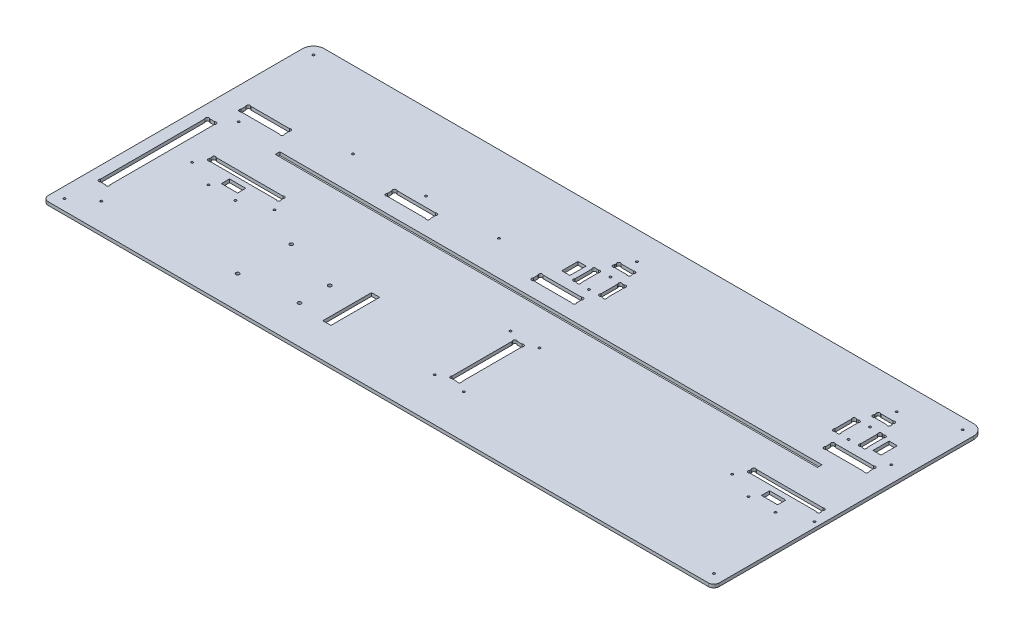
from build123d import *

# Parameters (mm, degrees)
ESQUISSE1_R             = 1
EXTRUSION1_DEPTH        = 3
ESQUISSE2_W             = 501
ESQUISSE2_H             = 4.2
ENL_V_MAT_EXTRU_1_DEPTH = 4
ESQUISSE3_R             = 1
ENL_V_MAT_EXTRU_2_DEPTH = 4
CONG_1_R                = 5
ESQUISSE4_R             = 1
ENL_V_MAT_EXTRU_3_DEPTH = 4
ESQUISSE5_R             = 1.59
ENL_V_MAT_EXTRU_4_DEPTH = 4
ESQUISSE6_W             = 15
ESQUISSE6_H             = 7.5
ESQUISSE6_W_2           = 7.5
ESQUISSE6_H_2           = 15
ESQUISSE6_H_3           = 45
ENL_V_MAT_EXTRU_5_DEPTH = 4
ESQUISSE7_R             = 1
ENL_V_MAT_EXTRU_6_DEPTH = 4
ESQUISSE8_R             = 1
ENL_V_MAT_EXTRU_7_DEPTH = 4


with BuildPart() as part:
    # Esquisse1 → Extrusion1 (new body)
    with BuildSketch(Plane(origin=(0, 0, 0), x_dir=(1, 0, 0), z_dir=(0, 1, 0))):
        with BuildLine():
            Line((10, 250), (610, 250))
            ThreePointArc((610, 250), (617.071067812, 247.071067812), (620, 240))
            Line((620, 240), (620, 0))
            Line((620, 0), (0, 0))
            Line((0, 0), (0, 240))
            ThreePointArc((0, 240), (2.928932188, 247.071067812), (10, 250))
        make_face()
        with Locations(Location((539, 98, 0), (0, 0, 270))):  # turned: the seam where the file's is
            Circle(ESQUISSE1_R, mode=Mode.SUBTRACT)
        with Locations(Location((615, 98, 0), (0, 0, 270))):  # turned: the seam where the file's is
            Circle(ESQUISSE1_R, mode=Mode.SUBTRACT)
        with BuildLine():
            Line((317, 211.2627417), (317, 212.7372583))
            ThreePointArc((317, 212.7372583), (317, 215), (319.2627417, 215))
            Line((319.2627417, 215), (330.7372583, 215))
            ThreePointArc((330.7372583, 215), (333, 215), (333, 212.7372583))
            Line((333, 212.7372583), (333, 211.2627417))
            ThreePointArc((333, 211.2627417), (333, 209), (330.737258301, 209))
            Line((330.737258301, 209), (319.262741699, 209))
            ThreePointArc((319.262741699, 209), (316.999999999, 209.000000001), (317, 211.2627417))
        make_face(mode=Mode.SUBTRACT)
        with BuildLine():
            Line((312.262741699, 179.5), (313.737258301, 179.5))
            ThreePointArc((313.737258301, 179.5), (316.000000001, 179.500000001), (316, 181.762741701))
            Line((316, 181.762741701), (316, 197.237258299))
            ThreePointArc((316, 197.237258299), (316.000000001, 199.499999999), (313.737258301, 199.5))
            Line((313.737258301, 199.5), (312.262741699, 199.5))
            ThreePointArc((312.262741699, 199.5), (309.999999999, 199.499999999), (310, 197.237258299))
            Line((310, 197.237258299), (310, 181.762741701))
            ThreePointArc((310, 181.762741701), (309.999999999, 179.500000001), (312.262741699, 179.5))
        make_face(mode=Mode.SUBTRACT)
        with BuildLine():
            Line((334, 181.762741701), (334, 197.2372583))
            ThreePointArc((334, 197.2372583), (334, 199.5), (336.2627417, 199.5))
            Line((336.2627417, 199.5), (337.7372583, 199.5))
            ThreePointArc((337.7372583, 199.5), (340, 199.5), (340, 197.2372583))
            Line((340, 197.2372583), (340, 181.762741701))
            ThreePointArc((340, 181.762741701), (340.000000001, 179.500000001), (337.737258301, 179.5))
            Line((337.737258301, 179.5), (336.262741699, 179.5))
            ThreePointArc((336.262741699, 179.5), (333.999999999, 179.500000001), (334, 181.762741701))
        make_face(mode=Mode.SUBTRACT)
        with BuildLine():
            Line((552.2627417, 179.5), (553.7372583, 179.5))
            ThreePointArc((553.7372583, 179.5), (556, 179.5), (556, 181.7627417))
            Line((556, 181.7627417), (556, 197.2372583))
            ThreePointArc((556, 197.2372583), (556, 199.5), (553.7372583, 199.5))
            Line((553.7372583, 199.5), (552.2627417, 199.5))
            ThreePointArc((552.2627417, 199.5), (550, 199.5), (550, 197.2372583))
            Line((550, 197.2372583), (550, 181.7627417))
            ThreePointArc((550, 181.7627417), (550, 179.5), (552.2627417, 179.5))
        make_face(mode=Mode.SUBTRACT)
        with BuildLine():
            Line((574, 181.7627417), (574, 197.2372583))
            ThreePointArc((574, 197.2372583), (574, 199.5), (576.2627417, 199.5))
            Line((576.2627417, 199.5), (577.7372583, 199.5))
            ThreePointArc((577.7372583, 199.5), (580, 199.5), (580, 197.2372583))
            Line((580, 197.2372583), (580, 181.7627417))
            ThreePointArc((580, 181.7627417), (580, 179.5), (577.7372583, 179.5))
            Line((577.7372583, 179.5), (576.2627417, 179.5))
            ThreePointArc((576.2627417, 179.5), (574, 179.5), (574, 181.7627417))
        make_face(mode=Mode.SUBTRACT)
        with BuildLine():
            Line((559.2627417, 209), (570.7372583, 209))
            ThreePointArc((570.7372583, 209), (573, 209), (573, 211.2627417))
            Line((573, 211.2627417), (573, 212.7372583))
            ThreePointArc((573, 212.7372583), (573, 215), (570.7372583, 215))
            Line((570.7372583, 215), (559.2627417, 215))
            ThreePointArc((559.2627417, 215), (557, 215), (557, 212.7372583))
            Line((557, 212.7372583), (557, 211.2627417))
            ThreePointArc((557, 211.2627417), (557, 209), (559.2627417, 209))
        make_face(mode=Mode.SUBTRACT)
        with BuildLine():
            Line((560, 167.7372583), (560, 163.2627417))
            ThreePointArc((560, 163.2627417), (560, 161), (562.2627417, 161))
            Line((562.2627417, 161), (597.7372583, 161))
            ThreePointArc((597.7372583, 161), (600, 161), (600, 163.2627417))
            Line((600, 163.2627417), (600, 167.7372583))
            ThreePointArc((600, 167.7372583), (600, 170), (597.7372583, 170))
            Line((597.7372583, 170), (562.2627417, 170))
            ThreePointArc((562.2627417, 170), (560, 170), (560, 167.7372583))
        make_face(mode=Mode.SUBTRACT)
        with BuildLine():
            Line((292.2627417, 161), (327.7372583, 161))
            ThreePointArc((327.7372583, 161), (330, 161), (330, 163.2627417))
            Line((330, 163.2627417), (330, 167.7372583))
            ThreePointArc((330, 167.7372583), (330, 170), (327.7372583, 170))
            Line((327.7372583, 170), (292.2627417, 170))
            ThreePointArc((292.2627417, 170), (290, 170), (290, 167.7372583))
            Line((290, 167.7372583), (290, 163.2627417))
            ThreePointArc((290, 163.2627417), (290, 161), (292.2627417, 161))
        make_face(mode=Mode.SUBTRACT)
        with BuildLine():
            Line((20, 167.7372583), (20, 163.2627417))
            ThreePointArc((20, 163.2627417), (20, 161), (22.2627417, 161))
            Line((22.2627417, 161), (57.7372583, 161))
            ThreePointArc((57.7372583, 161), (60, 161), (60, 163.2627417))
            Line((60, 163.2627417), (60, 167.7372583))
            ThreePointArc((60, 167.7372583), (60, 170), (57.7372583, 170))
            Line((57.7372583, 170), (22.2627417, 170))
            ThreePointArc((22.2627417, 170), (20, 170), (20, 167.7372583))
        make_face(mode=Mode.SUBTRACT)
        with BuildLine():
            Line((155, 167.7372583), (155, 163.2627417))
            ThreePointArc((155, 163.2627417), (155, 161), (157.2627417, 161))
            Line((157.2627417, 161), (192.7372583, 161))
            ThreePointArc((192.7372583, 161), (195, 161), (195, 163.2627417))
            Line((195, 163.2627417), (195, 167.7372583))
            ThreePointArc((195, 167.7372583), (195, 170), (192.7372583, 170))
            Line((192.7372583, 170), (157.2627417, 170))
            ThreePointArc((157.2627417, 170), (155, 170), (155, 167.7372583))
        make_face(mode=Mode.SUBTRACT)
        with BuildLine():
            Line((13.2627417, 40), (17.7372583, 40))
            ThreePointArc((17.7372583, 40), (20, 40), (20, 42.2627417))
            Line((20, 42.2627417), (20, 138.7372583))
            ThreePointArc((20, 138.7372583), (20, 141), (17.7372583, 141))
            Line((17.7372583, 141), (13.2627417, 141))
            ThreePointArc((13.2627417, 141), (11, 141), (11, 138.7372583))
            Line((11, 138.7372583), (11, 42.2627417))
            ThreePointArc((11, 42.2627417), (11, 40), (13.2627417, 40))
        make_face(mode=Mode.SUBTRACT)
        with BuildLine():
            Line((337.7372583, 45), (333.2627417, 45))
            ThreePointArc((333.2627417, 45), (331, 45), (331, 47.2627417))
            Line((331, 47.2627417), (331, 102.7372583))
            ThreePointArc((331, 102.7372583), (331, 105), (333.2627417, 105))
            Line((333.2627417, 105), (337.7372583, 105))
            ThreePointArc((337.7372583, 105), (340, 105), (340, 102.7372583))
            Line((340, 102.7372583), (340, 47.2627417))
            ThreePointArc((340, 47.2627417), (340, 45), (337.7372583, 45))
        make_face(mode=Mode.SUBTRACT)
        with BuildLine():
            Line((610, 109.2627417), (610, 110.7372583))
            ThreePointArc((610, 110.7372583), (610, 113), (607.7372583, 113))
            Line((607.7372583, 113), (546.2627417, 113))
            ThreePointArc((546.2627417, 113), (544, 113), (544, 110.7372583))
            Line((544, 110.7372583), (544, 109.2627417))
            ThreePointArc((544, 109.2627417), (544, 107), (546.2627417, 107))
            Line((546.2627417, 107), (607.7372583, 107))
            ThreePointArc((607.7372583, 107), (610, 107), (610, 109.2627417))
        make_face(mode=Mode.SUBTRACT)
        with BuildLine():
            Line((108.7372583, 113), (47.2627417, 113))
            ThreePointArc((47.2627417, 113), (45, 113), (45, 110.7372583))
            Line((45, 110.7372583), (45, 109.2627417))
            ThreePointArc((45, 109.2627417), (45, 107), (47.2627417, 107))
            Line((47.2627417, 107), (108.7372583, 107))
            ThreePointArc((108.7372583, 107), (111, 107), (111, 109.2627417))
            Line((111, 109.2627417), (111, 110.7372583))
            ThreePointArc((111, 110.7372583), (111, 113), (108.7372583, 113))
        make_face(mode=Mode.SUBTRACT)
    extrude(amount=EXTRUSION1_DEPTH)

    # Esquisse2 → Enlèv. mat.-Extru.1 (cut, through all)
    with BuildSketch(Plane(origin=(0, 3, 0), x_dir=(-1, 0, 0), z_dir=(0, 1, 0))):
        with Locations((-322.5, -144.9)):
            Rectangle(ESQUISSE2_W, ESQUISSE2_H)
    extrude(amount=-ENL_V_MAT_EXTRU_1_DEPTH, mode=Mode.SUBTRACT)

    # Esquisse3 → Enlèv. mat.-Extru.2 (cut, through all)
    with BuildSketch(Plane(origin=(0, 3, 0), x_dir=(1, 0, 0), z_dir=(0, 1, 0))):
        with Locations(Location((565, 179.5, 0), (0, 0, 270))):  # turned: the seam where the file's is
            Circle(ESQUISSE3_R)
        with Locations(Location((565, 199.5, 0), (0, 0, 270))):  # turned: the seam where the file's is
            Circle(ESQUISSE3_R)
        with Locations(Location((325, 179.5, 0), (0, 0, 270))):  # turned: the seam where the file's is
            Circle(ESQUISSE3_R)
        with Locations(Location((325, 199.5, 0), (0, 0, 270))):  # turned: the seam where the file's is
            Circle(ESQUISSE3_R)
    extrude(amount=-ENL_V_MAT_EXTRU_2_DEPTH, mode=Mode.SUBTRACT)

    # Congé1
    cong_1_edges = [part.edges().sort_by_distance(p)[0] for p in [
        (620, 1.5, 0),
        (0, 1.5, 0),
    ]]
    fillet(cong_1_edges, radius=CONG_1_R)

    # Esquisse4 → Enlèv. mat.-Extru.3 (cut, through all)
    with BuildSketch(Plane.XZ):
        with Locations(Location((10, -10, 0), (0, 0, 270))):  # turned: the seam where the file's is
            Circle(ESQUISSE4_R)
        with Locations(Location((610, -10, 0), (0, 0, 270))):  # turned: the seam where the file's is
            Circle(ESQUISSE4_R)
        with Locations(Location((610, -240, 0), (0, 0, 270))):  # turned: the seam where the file's is
            Circle(ESQUISSE4_R)
        with Locations(Location((10, -240, 0), (0, 0, 270))):  # turned: the seam where the file's is
            Circle(ESQUISSE4_R)
    extrude(amount=-ENL_V_MAT_EXTRU_3_DEPTH, mode=Mode.SUBTRACT)

    # Esquisse5 → Enlèv. mat.-Extru.4 (cut, through all)
    with BuildSketch(Plane(origin=(0, 3, 0), x_dir=(1, 0, 0), z_dir=(0, 1, 0))):
        with Locations(Location((151.27, 78.26, 0), (0, 0, 270))):  # turned: the seam where the file's is
            Circle(ESQUISSE5_R)
        with Locations(Location((150, 30, 0), (0, 0, 270))):  # turned: the seam where the file's is
            Circle(ESQUISSE5_R)
        with Locations(Location((202.07, 63.02, 0), (0, 0, 270))):  # turned: the seam where the file's is
            Circle(ESQUISSE5_R)
        with Locations(Location((202.07, 35.08, 0), (0, 0, 270))):  # turned: the seam where the file's is
            Circle(ESQUISSE5_R)
    extrude(amount=-ENL_V_MAT_EXTRU_4_DEPTH, mode=Mode.SUBTRACT)

    # Esquisse6 → Enlèv. mat.-Extru.5 (cut, through all)
    with BuildSketch(Plane(origin=(0, 3, 0), x_dir=(1, 0, 0), z_dir=(0, 1, 0))):
        with Locations((577, 98.25)):
            Rectangle(ESQUISSE6_W, ESQUISSE6_H)
        with Locations((588.75, 189.5)):
            Rectangle(ESQUISSE6_W_2, ESQUISSE6_H_2)
        with Locations((301.25, 189.5)):
            Rectangle(ESQUISSE6_W_2, ESQUISSE6_H_2)
        with Locations((230.82, 54.13)):
            Rectangle(ESQUISSE6_W_2, ESQUISSE6_H_3)
        with Locations((78, 98.25)):
            Rectangle(ESQUISSE6_W, ESQUISSE6_H)
    extrude(amount=-ENL_V_MAT_EXTRU_5_DEPTH, mode=Mode.SUBTRACT)

    # Esquisse7 → Enlèv. mat.-Extru.6 (cut, through all)
    with BuildSketch(Plane(origin=(0, 3, 0), x_dir=(1, 0, 0), z_dir=(0, 1, 0))):
        with Locations(Location((589.5, 87.5, 0), (0, 0, 270))):  # turned: the seam where the file's is
            Circle(ESQUISSE7_R)
        with Locations(Location((564.5, 87.5, 0), (0, 0, 270))):  # turned: the seam where the file's is
            Circle(ESQUISSE7_R)
        with Locations(Location((65.5, 87.5, 0), (0, 0, 270))):  # turned: the seam where the file's is
            Circle(ESQUISSE7_R)
        with Locations(Location((90.5, 87.5, 0), (0, 0, 270))):  # turned: the seam where the file's is
            Circle(ESQUISSE7_R)
        with Locations(Location((116, 98, 0), (0, 0, 270))):  # turned: the seam where the file's is
            Circle(ESQUISSE7_R)
        with Locations(Location((40, 98, 0), (0, 0, 270))):  # turned: the seam where the file's is
            Circle(ESQUISSE7_R)
    extrude(amount=-ENL_V_MAT_EXTRU_6_DEPTH, mode=Mode.SUBTRACT)

    # Esquisse8 → Enlèv. mat.-Extru.7 (cut, through all)
    with BuildSketch(Plane(origin=(0, 3, 0), x_dir=(1, 0, 0), z_dir=(0, 1, 0))):
        with Locations(Location((29, 25, 0), (0, 0, 270))):  # turned: the seam where the file's is
            Circle(ESQUISSE8_R)
        with Locations(Location((29, 152, 0), (0, 0, 270))):  # turned: the seam where the file's is
            Circle(ESQUISSE8_R)
        with Locations(Location((107.5, 179, 0), (0, 0, 270))):  # turned: the seam where the file's is
            Circle(ESQUISSE8_R)
        with Locations(Location((242.5, 179, 0), (0, 0, 270))):  # turned: the seam where the file's is
            Circle(ESQUISSE8_R)
        with Locations(Location((175, 179, 0), (0, 0, 270))):  # turned: the seam where the file's is
            Circle(ESQUISSE8_R)
        with Locations(Location((325, 224, 0), (0, 0, 270))):  # turned: the seam where the file's is
            Circle(ESQUISSE8_R)
        with Locations(Location((565, 224, 0), (0, 0, 270))):  # turned: the seam where the file's is
            Circle(ESQUISSE8_R)
        with Locations(Location((605, 179, 0), (0, 0, 270))):  # turned: the seam where the file's is
            Circle(ESQUISSE8_R)
        with Locations(Location((322, 40, 0), (0, 0, 270))):  # turned: the seam where the file's is
            Circle(ESQUISSE8_R)
        with Locations(Location((322, 110, 0), (0, 0, 270))):  # turned: the seam where the file's is
            Circle(ESQUISSE8_R)
        with Locations(Location((349, 110, 0), (0, 0, 270))):  # turned: the seam where the file's is
            Circle(ESQUISSE8_R)
        with Locations(Location((349, 40, 0), (0, 0, 270))):  # turned: the seam where the file's is
            Circle(ESQUISSE8_R)
    extrude(amount=-ENL_V_MAT_EXTRU_7_DEPTH, mode=Mode.SUBTRACT)


solid = part.part
